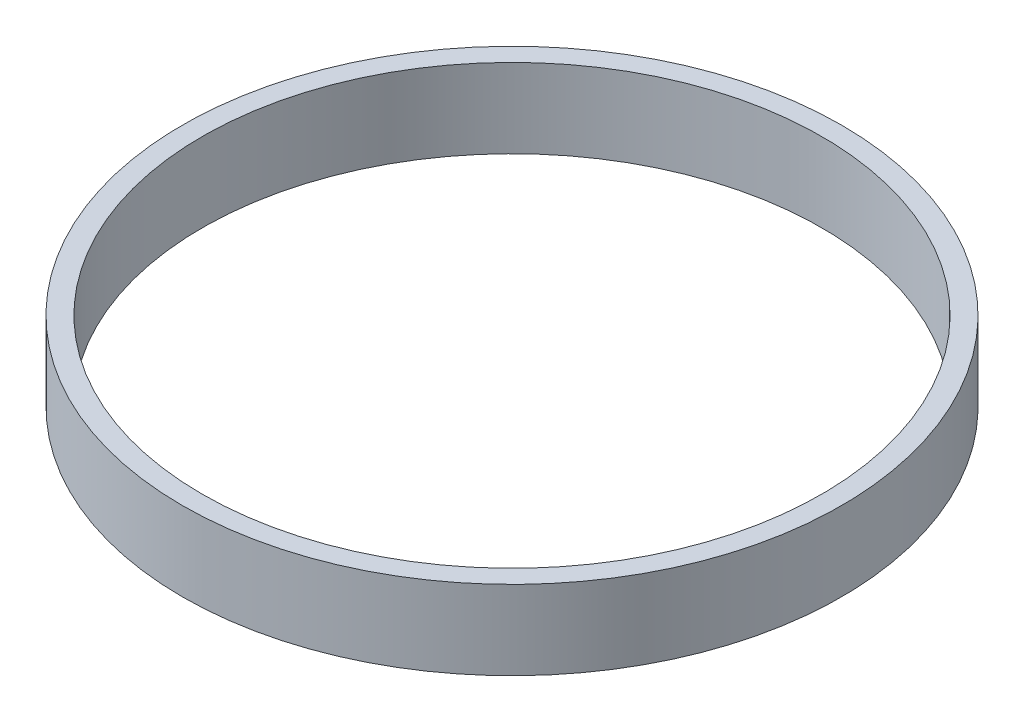
from build123d import *

# Parameters (mm, degrees)
SKETCH1_R           = 25
SKETCH1_R_2         = 23.5
BOSS_EXTRUDE1_DEPTH = 6


with BuildPart() as part:
    # Sketch1 → Boss-Extrude1 (new body)
    with BuildSketch(Plane(origin=(0, 0, 0), x_dir=(1, 0, 0), z_dir=(0, 1, 0))):
        Circle(SKETCH1_R)
        Circle(SKETCH1_R_2, mode=Mode.SUBTRACT)
    extrude(amount=BOSS_EXTRUDE1_DEPTH)


solid = part.part
